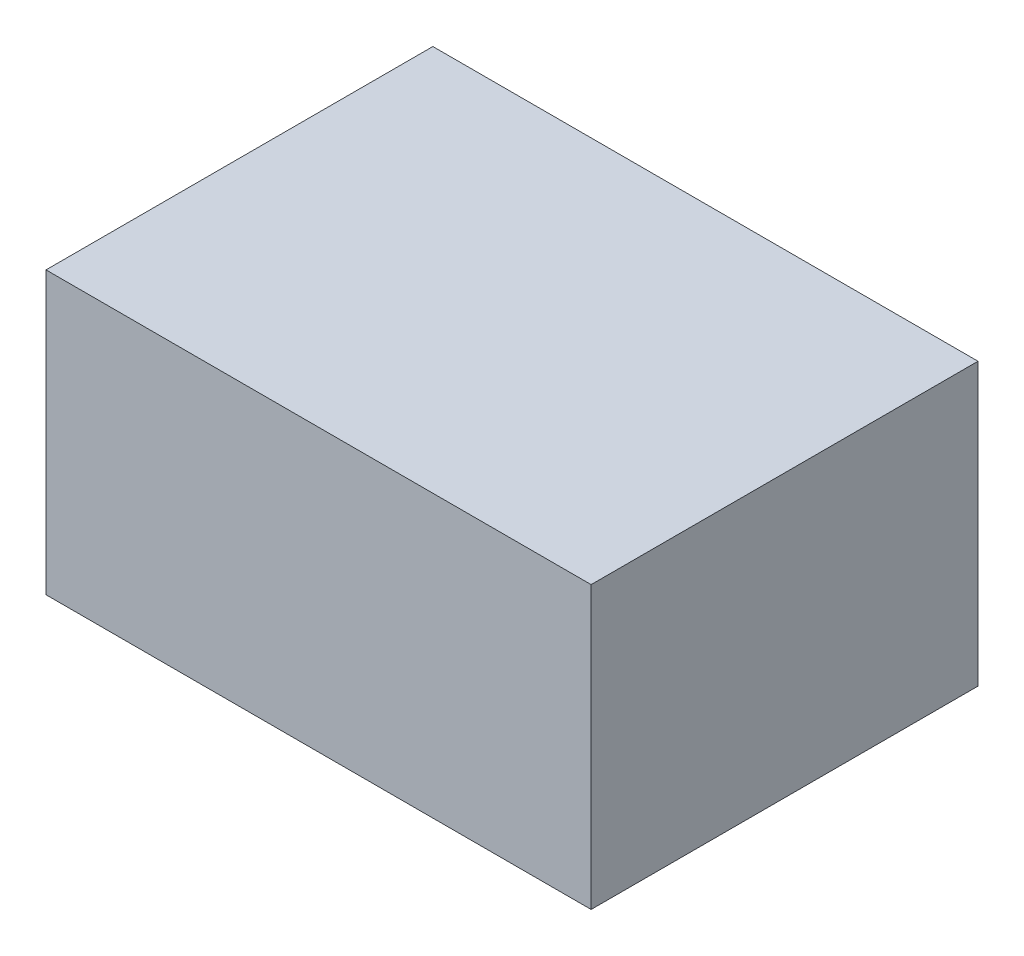
from build123d import *

# Parameters (mm, degrees)
SKETCH1_W           = 62
SKETCH1_H           = 44
BOSS_EXTRUDE1_DEPTH = 32


with BuildPart() as part:
    # Sketch1 → Boss-Extrude1 (new body)
    with BuildSketch(Plane(origin=(0, 0, 0), x_dir=(1, 0, 0), z_dir=(0, 1, 0))):
        with Locations((31, 22)):
            Rectangle(SKETCH1_W, SKETCH1_H)
    extrude(amount=BOSS_EXTRUDE1_DEPTH)


solid = part.part
